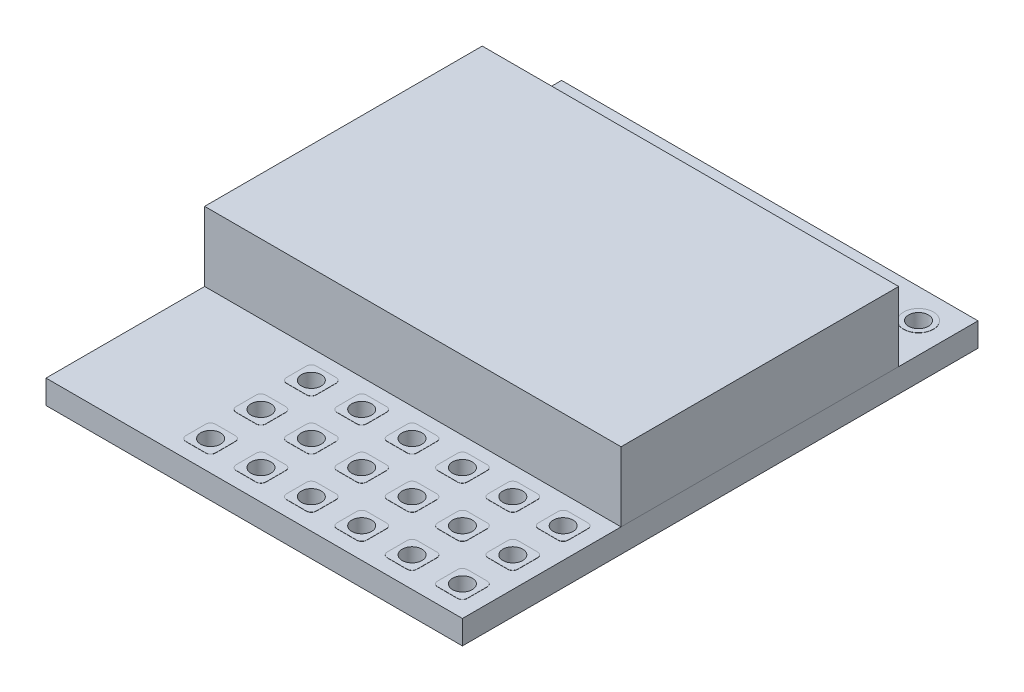
from build123d import *

# Parameters (mm, degrees)
SKETCH1_W           = 21
SKETCH1_H           = 26
BOSS_EXTRUDE1_DEPTH = 1.2
SKETCH3_W           = 21
SKETCH3_H           = 14
BOSS_EXTRUDE2_DEPTH = 3.5
SKETCH4_R           = 0.5
BOSS_EXTRUDE3_DEPTH = 0.01
SKETCH6_R           = 0.5
CUT_EXTRUDE1_DEPTH  = 4
SKETCH7_R           = 0.75
SKETCH7_R_2         = 0.5
BOSS_EXTRUDE4_DEPTH = 0.01
SKETCH8_R           = 0.5
CUT_EXTRUDE2_DEPTH  = 4


with BuildPart() as part:
    # Sketch1 → Boss-Extrude1 (new body)
    with BuildSketch(Plane(origin=(0, 0, 0), x_dir=(1, 0, 0), z_dir=(0, 1, 0))):
        with Locations((10.5, 13)):
            Rectangle(SKETCH1_W, SKETCH1_H)
    extrude(amount=BOSS_EXTRUDE1_DEPTH)

    # Sketch4 → Boss-Extrude3 (add)
    with BuildSketch(Plane(origin=(0, 1.2, 0), x_dir=(1, 0, 0), z_dir=(0, 1, 0))):
        with BuildLine():
            Line((19, 2.25), (20, 2.25))
            ThreePointArc((20, 2.25), (20.176776695, 2.176776695), (20.25, 2))
            Line((20.25, 2), (20.25, 1))
            ThreePointArc((20.25, 1), (20.176776695, 0.823223305), (20, 0.75))
            Line((20, 0.75), (19, 0.75))
            ThreePointArc((19, 0.75), (18.823223305, 0.823223305), (18.75, 1))
            Line((18.75, 1), (18.75, 2))
            ThreePointArc((18.75, 2), (18.823223305, 2.176776695), (19, 2.25))
        make_face()
        with Locations((19.5, 1.5)):
            Circle(SKETCH4_R, mode=Mode.SUBTRACT)
        with BuildLine():
            Line((16.46, 2.25), (17.46, 2.25))
            ThreePointArc((17.46, 2.25), (17.636776695, 2.176776695), (17.71, 2))
            Line((17.71, 2), (17.71, 1))
            ThreePointArc((17.71, 1), (17.636776695, 0.823223305), (17.46, 0.75))
            Line((17.46, 0.75), (16.46, 0.75))
            ThreePointArc((16.46, 0.75), (16.283223305, 0.823223305), (16.21, 1))
            Line((16.21, 1), (16.21, 2))
            ThreePointArc((16.21, 2), (16.283223305, 2.176776695), (16.46, 2.25))
        make_face()
        with Locations((16.96, 1.5)):
            Circle(SKETCH4_R, mode=Mode.SUBTRACT)
        with BuildLine():
            Line((13.92, 2.25), (14.92, 2.25))
            ThreePointArc((14.92, 2.25), (15.096776695, 2.176776695), (15.17, 2))
            Line((15.17, 2), (15.17, 1))
            ThreePointArc((15.17, 1), (15.096776695, 0.823223305), (14.92, 0.75))
            Line((14.92, 0.75), (13.92, 0.75))
            ThreePointArc((13.92, 0.75), (13.743223305, 0.823223305), (13.67, 1))
            Line((13.67, 1), (13.67, 2))
            ThreePointArc((13.67, 2), (13.743223305, 2.176776695), (13.92, 2.25))
        make_face()
        with Locations((14.42, 1.5)):
            Circle(SKETCH4_R, mode=Mode.SUBTRACT)
        with BuildLine():
            Line((11.38, 2.25), (12.38, 2.25))
            ThreePointArc((12.38, 2.25), (12.556776695, 2.176776695), (12.63, 2))
            Line((12.63, 2), (12.63, 1))
            ThreePointArc((12.63, 1), (12.556776695, 0.823223305), (12.38, 0.75))
            Line((12.38, 0.75), (11.38, 0.75))
            ThreePointArc((11.38, 0.75), (11.203223305, 0.823223305), (11.13, 1))
            Line((11.13, 1), (11.13, 2))
            ThreePointArc((11.13, 2), (11.203223305, 2.176776695), (11.38, 2.25))
        make_face()
        with Locations((11.88, 1.5)):
            Circle(SKETCH4_R, mode=Mode.SUBTRACT)
        with BuildLine():
            Line((8.84, 2.25), (9.84, 2.25))
            ThreePointArc((9.84, 2.25), (10.016776695, 2.176776695), (10.09, 2))
            Line((10.09, 2), (10.09, 1))
            ThreePointArc((10.09, 1), (10.016776695, 0.823223305), (9.84, 0.75))
            Line((9.84, 0.75), (8.84, 0.75))
            ThreePointArc((8.84, 0.75), (8.663223305, 0.823223305), (8.59, 1))
            Line((8.59, 1), (8.59, 2))
            ThreePointArc((8.59, 2), (8.663223305, 2.176776695), (8.84, 2.25))
        make_face()
        with Locations((9.34, 1.5)):
            Circle(SKETCH4_R, mode=Mode.SUBTRACT)
        with BuildLine():
            Line((6.3, 2.25), (7.3, 2.25))
            ThreePointArc((7.3, 2.25), (7.476776695, 2.176776695), (7.55, 2))
            Line((7.55, 2), (7.55, 1))
            ThreePointArc((7.55, 1), (7.476776695, 0.823223305), (7.3, 0.75))
            Line((7.3, 0.75), (6.3, 0.75))
            ThreePointArc((6.3, 0.75), (6.123223305, 0.823223305), (6.05, 1))
            Line((6.05, 1), (6.05, 2))
            ThreePointArc((6.05, 2), (6.123223305, 2.176776695), (6.3, 2.25))
        make_face()
        with Locations((6.8, 1.5)):
            Circle(SKETCH4_R, mode=Mode.SUBTRACT)
        with BuildLine():
            Line((16.46, 4.79), (17.46, 4.79))
            ThreePointArc((17.46, 4.79), (17.636776695, 4.716776695), (17.71, 4.54))
            Line((17.71, 4.54), (17.71, 3.54))
            ThreePointArc((17.71, 3.54), (17.636776695, 3.363223305), (17.46, 3.29))
            Line((17.46, 3.29), (16.46, 3.29))
            ThreePointArc((16.46, 3.29), (16.283223305, 3.363223305), (16.21, 3.54))
            Line((16.21, 3.54), (16.21, 4.54))
            ThreePointArc((16.21, 4.54), (16.283223305, 4.716776695), (16.46, 4.79))
        make_face()
        with Locations((16.96, 4.04)):
            Circle(SKETCH4_R, mode=Mode.SUBTRACT)
        with BuildLine():
            Line((13.92, 4.79), (14.92, 4.79))
            ThreePointArc((14.92, 4.79), (15.096776695, 4.716776695), (15.17, 4.54))
            Line((15.17, 4.54), (15.17, 3.54))
            ThreePointArc((15.17, 3.54), (15.096776695, 3.363223305), (14.92, 3.29))
            Line((14.92, 3.29), (13.92, 3.29))
            ThreePointArc((13.92, 3.29), (13.743223305, 3.363223305), (13.67, 3.54))
            Line((13.67, 3.54), (13.67, 4.54))
            ThreePointArc((13.67, 4.54), (13.743223305, 4.716776695), (13.92, 4.79))
        make_face()
        with Locations((14.42, 4.04)):
            Circle(SKETCH4_R, mode=Mode.SUBTRACT)
        with BuildLine():
            Line((11.38, 4.79), (12.38, 4.79))
            ThreePointArc((12.38, 4.79), (12.556776695, 4.716776695), (12.63, 4.54))
            Line((12.63, 4.54), (12.63, 3.54))
            ThreePointArc((12.63, 3.54), (12.556776695, 3.363223305), (12.38, 3.29))
            Line((12.38, 3.29), (11.38, 3.29))
            ThreePointArc((11.38, 3.29), (11.203223305, 3.363223305), (11.13, 3.54))
            Line((11.13, 3.54), (11.13, 4.54))
            ThreePointArc((11.13, 4.54), (11.203223305, 4.716776695), (11.38, 4.79))
        make_face()
        with Locations((11.88, 4.04)):
            Circle(SKETCH4_R, mode=Mode.SUBTRACT)
        with BuildLine():
            Line((8.84, 4.79), (9.84, 4.79))
            ThreePointArc((9.84, 4.79), (10.016776695, 4.716776695), (10.09, 4.54))
            Line((10.09, 4.54), (10.09, 3.54))
            ThreePointArc((10.09, 3.54), (10.016776695, 3.363223305), (9.84, 3.29))
            Line((9.84, 3.29), (8.84, 3.29))
            ThreePointArc((8.84, 3.29), (8.663223305, 3.363223305), (8.59, 3.54))
            Line((8.59, 3.54), (8.59, 4.54))
            ThreePointArc((8.59, 4.54), (8.663223305, 4.716776695), (8.84, 4.79))
        make_face()
        with Locations((9.34, 4.04)):
            Circle(SKETCH4_R, mode=Mode.SUBTRACT)
        with BuildLine():
            Line((6.3, 4.79), (7.3, 4.79))
            ThreePointArc((7.3, 4.79), (7.476776695, 4.716776695), (7.55, 4.54))
            Line((7.55, 4.54), (7.55, 3.54))
            ThreePointArc((7.55, 3.54), (7.476776695, 3.363223305), (7.3, 3.29))
            Line((7.3, 3.29), (6.3, 3.29))
            ThreePointArc((6.3, 3.29), (6.123223305, 3.363223305), (6.05, 3.54))
            Line((6.05, 3.54), (6.05, 4.54))
            ThreePointArc((6.05, 4.54), (6.123223305, 4.716776695), (6.3, 4.79))
        make_face()
        with Locations((6.8, 4.04)):
            Circle(SKETCH4_R, mode=Mode.SUBTRACT)
        with BuildLine():
            Line((16.46, 7.33), (17.46, 7.33))
            ThreePointArc((17.46, 7.33), (17.636776695, 7.256776695), (17.71, 7.08))
            Line((17.71, 7.08), (17.71, 6.08))
            ThreePointArc((17.71, 6.08), (17.636776695, 5.903223305), (17.46, 5.83))
            Line((17.46, 5.83), (16.46, 5.83))
            ThreePointArc((16.46, 5.83), (16.283223305, 5.903223305), (16.21, 6.08))
            Line((16.21, 6.08), (16.21, 7.08))
            ThreePointArc((16.21, 7.08), (16.283223305, 7.256776695), (16.46, 7.33))
        make_face()
        with Locations((16.96, 6.58)):
            Circle(SKETCH4_R, mode=Mode.SUBTRACT)
        with BuildLine():
            Line((13.92, 7.33), (14.92, 7.33))
            ThreePointArc((14.92, 7.33), (15.096776695, 7.256776695), (15.17, 7.08))
            Line((15.17, 7.08), (15.17, 6.08))
            ThreePointArc((15.17, 6.08), (15.096776695, 5.903223305), (14.92, 5.83))
            Line((14.92, 5.83), (13.92, 5.83))
            ThreePointArc((13.92, 5.83), (13.743223305, 5.903223305), (13.67, 6.08))
            Line((13.67, 6.08), (13.67, 7.08))
            ThreePointArc((13.67, 7.08), (13.743223305, 7.256776695), (13.92, 7.33))
        make_face()
        with Locations((14.42, 6.58)):
            Circle(SKETCH4_R, mode=Mode.SUBTRACT)
        with BuildLine():
            Line((11.38, 7.33), (12.38, 7.33))
            ThreePointArc((12.38, 7.33), (12.556776695, 7.256776695), (12.63, 7.08))
            Line((12.63, 7.08), (12.63, 6.08))
            ThreePointArc((12.63, 6.08), (12.556776695, 5.903223305), (12.38, 5.83))
            Line((12.38, 5.83), (11.38, 5.83))
            ThreePointArc((11.38, 5.83), (11.203223305, 5.903223305), (11.13, 6.08))
            Line((11.13, 6.08), (11.13, 7.08))
            ThreePointArc((11.13, 7.08), (11.203223305, 7.256776695), (11.38, 7.33))
        make_face()
        with Locations((11.88, 6.58)):
            Circle(SKETCH4_R, mode=Mode.SUBTRACT)
        with BuildLine():
            Line((8.84, 7.33), (9.84, 7.33))
            ThreePointArc((9.84, 7.33), (10.016776695, 7.256776695), (10.09, 7.08))
            Line((10.09, 7.08), (10.09, 6.08))
            ThreePointArc((10.09, 6.08), (10.016776695, 5.903223305), (9.84, 5.83))
            Line((9.84, 5.83), (8.84, 5.83))
            ThreePointArc((8.84, 5.83), (8.663223305, 5.903223305), (8.59, 6.08))
            Line((8.59, 6.08), (8.59, 7.08))
            ThreePointArc((8.59, 7.08), (8.663223305, 7.256776695), (8.84, 7.33))
        make_face()
        with Locations((9.34, 6.58)):
            Circle(SKETCH4_R, mode=Mode.SUBTRACT)
        with BuildLine():
            Line((6.3, 7.33), (7.3, 7.33))
            ThreePointArc((7.3, 7.33), (7.476776695, 7.256776695), (7.55, 7.08))
            Line((7.55, 7.08), (7.55, 6.08))
            ThreePointArc((7.55, 6.08), (7.476776695, 5.903223305), (7.3, 5.83))
            Line((7.3, 5.83), (6.3, 5.83))
            ThreePointArc((6.3, 5.83), (6.123223305, 5.903223305), (6.05, 6.08))
            Line((6.05, 6.08), (6.05, 7.08))
            ThreePointArc((6.05, 7.08), (6.123223305, 7.256776695), (6.3, 7.33))
        make_face()
        with Locations((6.8, 6.58)):
            Circle(SKETCH4_R, mode=Mode.SUBTRACT)
        with BuildLine():
            Line((19, 4.79), (20, 4.79))
            ThreePointArc((20, 4.79), (20.176776695, 4.716776695), (20.25, 4.54))
            Line((20.25, 4.54), (20.25, 3.54))
            ThreePointArc((20.25, 3.54), (20.176776695, 3.363223305), (20, 3.29))
            Line((20, 3.29), (19, 3.29))
            ThreePointArc((19, 3.29), (18.823223305, 3.363223305), (18.75, 3.54))
            Line((18.75, 3.54), (18.75, 4.54))
            ThreePointArc((18.75, 4.54), (18.823223305, 4.716776695), (19, 4.79))
        make_face()
        with Locations((19.5, 4.04)):
            Circle(SKETCH4_R, mode=Mode.SUBTRACT)
        with BuildLine():
            Line((19, 7.33), (20, 7.33))
            ThreePointArc((20, 7.33), (20.176776695, 7.256776695), (20.25, 7.08))
            Line((20.25, 7.08), (20.25, 6.08))
            ThreePointArc((20.25, 6.08), (20.176776695, 5.903223305), (20, 5.83))
            Line((20, 5.83), (19, 5.83))
            ThreePointArc((19, 5.83), (18.823223305, 5.903223305), (18.75, 6.08))
            Line((18.75, 6.08), (18.75, 7.08))
            ThreePointArc((18.75, 7.08), (18.823223305, 7.256776695), (19, 7.33))
        make_face()
        with Locations((19.5, 6.58)):
            Circle(SKETCH4_R, mode=Mode.SUBTRACT)
    extrude(amount=BOSS_EXTRUDE3_DEPTH)

    # Sketch6 → Cut-Extrude1 (cut)
    with BuildSketch(Plane(origin=(0, 1.2, 0), x_dir=(1, 0, 0), z_dir=(0, 1, 0))):
        with Locations((9.34, 6.58)):
            Circle(SKETCH6_R)
        with Locations((9.34, 4.04)):
            Circle(SKETCH6_R)
        with Locations((11.88, 4.04)):
            Circle(SKETCH6_R)
        with Locations((14.42, 4.04)):
            Circle(SKETCH6_R)
        with Locations((16.96, 4.04)):
            Circle(SKETCH6_R)
        with Locations((19.5, 4.04)):
            Circle(SKETCH6_R)
        with Locations((19.5, 6.58)):
            Circle(SKETCH6_R)
        with Locations((16.96, 6.58)):
            Circle(SKETCH6_R)
        with Locations((14.42, 6.58)):
            Circle(SKETCH6_R)
        with Locations((11.88, 6.58)):
            Circle(SKETCH6_R)
        with Locations((6.8, 6.58)):
            Circle(SKETCH6_R)
        with Locations((6.8, 4.04)):
            Circle(SKETCH6_R)
        with Locations((6.8, 1.5)):
            Circle(SKETCH6_R)
        with Locations((9.34, 1.5)):
            Circle(SKETCH6_R)
        with Locations((11.88, 1.5)):
            Circle(SKETCH6_R)
        with Locations((14.42, 1.5)):
            Circle(SKETCH6_R)
        with Locations((16.96, 1.5)):
            Circle(SKETCH6_R)
        with Locations((19.5, 1.5)):
            Circle(SKETCH6_R)
    extrude(amount=-CUT_EXTRUDE1_DEPTH, mode=Mode.SUBTRACT)

    # Sketch7 → Boss-Extrude4 (add)
    with BuildSketch(Plane(origin=(0, 1.2, 0), x_dir=(1, 0, 0), z_dir=(0, 1, 0))):
        with Locations((19.5, 24.5)):
            Circle(SKETCH7_R)
        with Locations((19.5, 24.5)):
            Circle(SKETCH7_R_2, mode=Mode.SUBTRACT)
        with Locations((16.96, 24.5)):
            Circle(SKETCH7_R)
        with Locations((16.96, 24.5)):
            Circle(SKETCH7_R_2, mode=Mode.SUBTRACT)
        with Locations((14.42, 24.5)):
            Circle(SKETCH7_R)
        with Locations((14.42, 24.5)):
            Circle(SKETCH7_R_2, mode=Mode.SUBTRACT)
        with Locations((11.88, 24.5)):
            Circle(SKETCH7_R)
        with Locations((11.88, 24.5)):
            Circle(SKETCH7_R_2, mode=Mode.SUBTRACT)
        with Locations((9.34, 24.5)):
            Circle(SKETCH7_R)
        with Locations((9.34, 24.5)):
            Circle(SKETCH7_R_2, mode=Mode.SUBTRACT)
        with Locations((6.8, 24.5)):
            Circle(SKETCH7_R)
        with Locations((6.8, 24.5)):
            Circle(SKETCH7_R_2, mode=Mode.SUBTRACT)
        with Locations((4.26, 24.5)):
            Circle(SKETCH7_R)
        with Locations((4.26, 24.5)):
            Circle(SKETCH7_R_2, mode=Mode.SUBTRACT)
        with Locations((1.72, 24.5)):
            Circle(SKETCH7_R)
        with Locations((1.72, 24.5)):
            Circle(SKETCH7_R_2, mode=Mode.SUBTRACT)
    extrude(amount=BOSS_EXTRUDE4_DEPTH)

    # Sketch8 → Cut-Extrude2 (cut)
    with BuildSketch(Plane(origin=(0, 1.2, 0), x_dir=(1, 0, 0), z_dir=(0, 1, 0))):
        with Locations((19.5, 24.5)):
            Circle(SKETCH8_R)
        with Locations((16.96, 24.5)):
            Circle(SKETCH8_R)
        with Locations((14.42, 24.5)):
            Circle(SKETCH8_R)
        with Locations((11.88, 24.5)):
            Circle(SKETCH8_R)
        with Locations((9.34, 24.5)):
            Circle(SKETCH8_R)
        with Locations((6.8, 24.5)):
            Circle(SKETCH8_R)
        with Locations((4.26, 24.5)):
            Circle(SKETCH8_R)
        with Locations((1.72, 24.5)):
            Circle(SKETCH8_R)
    extrude(amount=-CUT_EXTRUDE2_DEPTH, mode=Mode.SUBTRACT)


with BuildPart() as body_2:
    # Sketch3 → Boss-Extrude2 (new body)
    with BuildSketch(Plane(origin=(0, 1.2, 0), x_dir=(1, 0, 0), z_dir=(0, 1, 0))):
        with Locations((10.5, 15)):
            Rectangle(SKETCH3_W, SKETCH3_H)
    extrude(amount=BOSS_EXTRUDE2_DEPTH)


solid = Compound([part.part, body_2.part])
